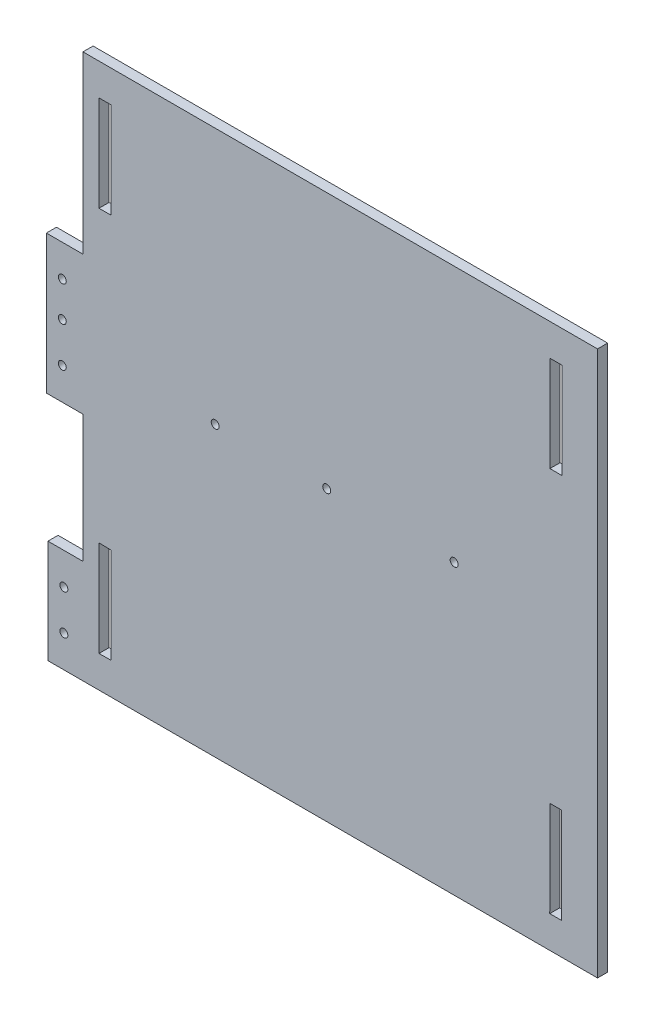
from build123d import *

# Parameters (mm, degrees)
MODEL_R             = 2.5
MODEL_W             = 7.5
MODEL_H             = 60.000012028
BOSS_EXTRUDE1_DEPTH = 6.35


with BuildPart() as part:
    # Model → Boss-Extrude1 (new body)
    with BuildSketch(Plane.XY):
        Polygon((691.840616937, 302.611489719), (346.840616937, 302.611489719), (346.840616937, 367.611489719), (368.840616937, 367.611489719), (368.840616937, 447.611489719), (345.840616937, 447.611489719), (345.840616937, 534.611489719), (368.840616937, 534.611489719), (368.840616937, 644.611489719), (691.840616937, 644.611489719), align=None)
        with Locations((355.840616937, 514.611489719)):
            Circle(MODEL_R, mode=Mode.SUBTRACT)
        with Locations((355.840616937, 492.611489719)):
            Circle(MODEL_R, mode=Mode.SUBTRACT)
        with Locations((355.840616937, 467.611489719)):
            Circle(MODEL_R, mode=Mode.SUBTRACT)
        with Locations((356.840616937, 347.611489719)):
            Circle(MODEL_R, mode=Mode.SUBTRACT)
        with Locations((356.840616937, 322.611489719)):
            Circle(MODEL_R, mode=Mode.SUBTRACT)
        with Locations((451.840616937, 483.611489719)):
            Circle(MODEL_R, mode=Mode.SUBTRACT)
        with Locations((521.840616937, 483.611489719)):
            Circle(MODEL_R, mode=Mode.SUBTRACT)
        with Locations((601.840616937, 483.611489719)):
            Circle(MODEL_R, mode=Mode.SUBTRACT)
        with Locations((382.628249379, 594.607051385)):
            Rectangle(MODEL_W, MODEL_H, mode=Mode.SUBTRACT)
        Polygon((378.878249379, 382.675054085), (386.377012819, 382.538867187), (386.377012819, 322.632601599), (378.878249379, 322.547926114), align=None, mode=Mode.SUBTRACT)
        Polygon((661.987313401, 624.611489719), (669.487313401, 624.611489719), (669.459063879, 564.611489719), (661.959063879, 564.611489719), align=None, mode=Mode.SUBTRACT)
        Polygon((661.873375206, 382.614770073), (669.373373543, 382.611238884), (669.345124024, 322.611245534), (661.845125687, 322.614776724), align=None, mode=Mode.SUBTRACT)
    extrude(amount=-BOSS_EXTRUDE1_DEPTH)


solid = part.part
